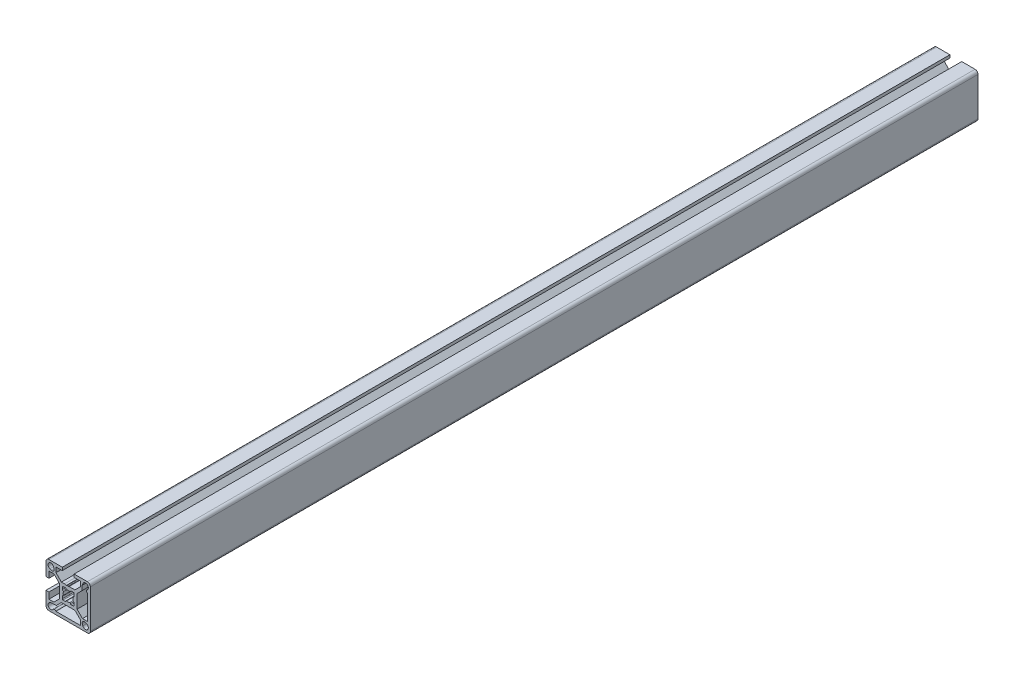
from build123d import *

# Parameters (mm, degrees)
ESTRUSIONE_ESTRUSIONE1_DEPTH = 600


with BuildPart() as part:
    # Schizzo1 → Estrusione-Estrusione1 (new body)
    with BuildSketch(Plane(origin=(0, 0, -600), x_dir=(-1, 0, 0), z_dir=(0, 0, -1))):
        with BuildLine():
            Line((-15, 13), (-15, -13))
            ThreePointArc((-15, -13), (-14.414213562, -14.414213562), (-13, -15))
            Line((-13, -15), (13, -15))
            ThreePointArc((13, -15), (14.414213562, -14.414213562), (15, -13))
            Line((15, -13), (15, -4))
            Line((15, -4), (13, -4))
            Line((13, -4), (13, -8.25))
            Line((13, -8.25), (9.664213562, -8.25))
            add(Edge.make_bspline(
                [(9.664213562, -8.25), (8.442809042, -7.028595479), (7.221404521, -5.807190958), (6, -4.585786438)],
                knots=[0, 0, 0, 0, 1, 1, 1, 1], degree=3))
            Line((6, -4.585786438), (6, -2.5))
            Line((6, -2.5), (5.750976629, -1.218885816))
            Line((5.750976629, -1.218885816), (5.933012788, -0.90358969))
            ThreePointArc((5.933012788, -0.90358969), (6, -0.653589753), (5.933012702, -0.403589838))
            Line((5.933012702, -0.403589838), (5.7, 0))
            Line((5.7, 0), (5.933012702, 0.403589838))
            ThreePointArc((5.933012702, 0.403589838), (5.982962913, 0.524180316), (6, 0.653589838))
            Line((6, 0.653589838), (6, 4.585786438))
            add(Edge.make_bspline(
                [(6, 4.585786438), (7.221404521, 5.807190958), (8.442809042, 7.028595479), (9.664213562, 8.25)],
                knots=[0, 0, 0, 0, 1, 1, 1, 1], degree=3))
            Line((9.664213562, 8.25), (13, 8.25))
            Line((13, 8.25), (13, 4))
            Line((13, 4), (15, 4))
            Line((15, 4), (15, 13))
            ThreePointArc((15, 13), (14.414213562, 14.414213562), (13, 15))
            Line((13, 15), (4, 15))
            Line((4, 15), (4, 13))
            Line((4, 13), (8.25, 13))
            Line((8.25, 13), (8.25, 9.664213562))
            add(Edge.make_bspline(
                [(8.25, 9.664213562), (7.028595479, 8.442809042), (5.807190958, 7.221404521), (4.585786438, 6)],
                knots=[0, 0, 0, 0, 1, 1, 1, 1], degree=3))
            Line((4.585786438, 6), (2.5, 6))
            Line((2.5, 6), (1.218885629, 5.750976592))
            Line((1.218885629, 5.750976592), (0.903589838, 5.933012702))
            ThreePointArc((0.903589838, 5.933012702), (0.653589838, 6), (0.403589838, 5.933012702))
            Line((0.403589838, 5.933012702), (0, 5.7))
            Line((0, 5.7), (-0.403589838, 5.933012702))
            ThreePointArc((-0.403589838, 5.933012702), (-0.524180316, 5.982962913), (-0.653589838, 6))
            Line((-0.653589838, 6), (-4.585786438, 6))
            add(Edge.make_bspline(
                [(-4.585786438, 6), (-5.807190958, 7.221404521), (-7.028595479, 8.442809042), (-8.25, 9.664213562)],
                knots=[0, 0, 0, 0, 1, 1, 1, 1], degree=3))
            Line((-8.25, 9.664213562), (-8.25, 13))
            Line((-8.25, 13), (-4, 13))
            Line((-4, 13), (-4, 15))
            Line((-4, 15), (-13, 15))
            ThreePointArc((-13, 15), (-14.414213562, 14.414213562), (-15, 13))
        make_face()
        with BuildLine():
            Line((12.349838066, 9.914583088), (11.34224826, 9.54785039))
            ThreePointArc((11.34224826, 9.54785039), (9.873470565, 9.873470565), (9.54785039, 11.34224826))
            Line((9.54785039, 11.34224826), (9.914583088, 12.349838066))
            ThreePointArc((9.914583088, 12.349838066), (13.043502884, 13.043502884), (12.349838066, 9.914583088))
        make_face(mode=Mode.SUBTRACT)
        with BuildLine():
            Line((-4.585786438, -6), (4.58, -6))
            add(Edge.make_bspline(
                [(4.58, -6), (5.73, -7.15), (6.88, -8.3), (8.03, -9.45)],
                knots=[0, 0, 0, 0, 1, 1, 1, 1], degree=3))
            Line((8.03, -9.45), (11.1, -9.45))
            Line((11.1, -9.45), (12.361944654, -9.919036981))
            ThreePointArc((12.361944654, -9.919036981), (13.194761433, -12.872897378), (10.127586207, -12.766543418))
            ThreePointArc((10.127586207, -12.766543418), (9.169403304, -12.336446483), (8.355281336, -13))
            Line((8.355281336, -13), (-8.25, -13))
            Line((-8.25, -13), (-8.25, -9.664213562))
            add(Edge.make_bspline(
                [(-8.25, -9.664213562), (-7.028595479, -8.442809042), (-5.807190958, -7.221404521), (-4.585786438, -6)],
                knots=[0, 0, 0, 0, 1, 1, 1, 1], degree=3))
        make_face(mode=Mode.SUBTRACT)
        with BuildLine():
            Line((-9.919036981, 12.361944654), (-9.45, 11.1))
            Line((-9.45, 11.1), (-9.45, 8.03))
            add(Edge.make_bspline(
                [(-9.45, 8.03), (-8.3, 6.88), (-7.15, 5.73), (-6, 4.58)],
                knots=[0, 0, 0, 0, 1, 1, 1, 1], degree=3))
            Line((-6, 4.58), (-6, -4.585786438))
            add(Edge.make_bspline(
                [(-6, -4.585786438), (-7.221404521, -5.807190958), (-8.442809042, -7.028595479), (-9.664213562, -8.25)],
                knots=[0, 0, 0, 0, 1, 1, 1, 1], degree=3))
            Line((-9.664213562, -8.25), (-13, -8.25))
            Line((-13, -8.25), (-13, 8.355281336))
            ThreePointArc((-13, 8.355281336), (-12.336446483, 9.169403304), (-12.766543418, 10.127586207))
            ThreePointArc((-12.766543418, 10.127586207), (-12.872897378, 13.194761433), (-9.919036981, 12.361944654))
        make_face(mode=Mode.SUBTRACT)
        with BuildLine():
            Line((-9.54785039, -11.34224826), (-9.914583088, -12.349838066))
            ThreePointArc((-9.914583088, -12.349838066), (-13.043502884, -13.043502884), (-12.349838066, -9.914583088))
            Line((-12.349838066, -9.914583088), (-11.34224826, -9.54785039))
            ThreePointArc((-11.34224826, -9.54785039), (-9.873470565, -9.873470565), (-9.54785039, -11.34224826))
        make_face(mode=Mode.SUBTRACT)
        with BuildLine():
            Line((4, 3.5), (4, 2))
            ThreePointArc((4, 2), (3.879005736, 1.673879391), (3.574581393, 1.505593673))
            ThreePointArc((3.574581393, 1.505593673), (3.295837094, 1.323326833), (3.251694243, 0.993219284))
            ThreePointArc((3.251694243, 0.993219284), (3.4, 0), (3.251694243, -0.993219284))
            ThreePointArc((3.251694243, -0.993219284), (3.295837094, -1.323326833), (3.574581393, -1.505593673))
            ThreePointArc((3.574581393, -1.505593673), (3.879005736, -1.673879391), (4, -2))
            Line((4, -2), (4, -3.5))
            ThreePointArc((4, -3.5), (3.853553391, -3.853553391), (3.5, -4))
            Line((3.5, -4), (2, -4))
            ThreePointArc((2, -4), (1.673879391, -3.879005736), (1.505593673, -3.574581393))
            ThreePointArc((1.505593673, -3.574581393), (1.323326833, -3.295837094), (0.993219284, -3.251694243))
            ThreePointArc((0.993219284, -3.251694243), (0, -3.4), (-0.993219284, -3.251694243))
            ThreePointArc((-0.993219284, -3.251694243), (-1.323326833, -3.295837094), (-1.505593673, -3.574581393))
            ThreePointArc((-1.505593673, -3.574581393), (-1.673879391, -3.879005736), (-2, -4))
            Line((-2, -4), (-3.5, -4))
            ThreePointArc((-3.5, -4), (-3.853553391, -3.853553391), (-4, -3.5))
            Line((-4, -3.5), (-4, -2))
            ThreePointArc((-4, -2), (-3.879005736, -1.673879391), (-3.574581393, -1.505593673))
            ThreePointArc((-3.574581393, -1.505593673), (-3.295837094, -1.323326833), (-3.251694243, -0.993219284))
            ThreePointArc((-3.251694243, -0.993219284), (-3.4, 0), (-3.251694243, 0.993219284))
            ThreePointArc((-3.251694243, 0.993219284), (-3.295837094, 1.323326833), (-3.574581393, 1.505593673))
            ThreePointArc((-3.574581393, 1.505593673), (-3.879005736, 1.673879391), (-4, 2))
            Line((-4, 2), (-4, 3.5))
            ThreePointArc((-4, 3.5), (-3.853553391, 3.853553391), (-3.5, 4))
            Line((-3.5, 4), (-2, 4))
            ThreePointArc((-2, 4), (-1.673879391, 3.879005736), (-1.505593673, 3.574581393))
            ThreePointArc((-1.505593673, 3.574581393), (-1.323326833, 3.295837094), (-0.993219284, 3.251694243))
            ThreePointArc((-0.993219284, 3.251694243), (0, 3.4), (0.993219284, 3.251694243))
            ThreePointArc((0.993219284, 3.251694243), (1.323326833, 3.295837094), (1.505593673, 3.574581393))
            ThreePointArc((1.505593673, 3.574581393), (1.673879391, 3.879005736), (2, 4))
            Line((2, 4), (3.5, 4))
            ThreePointArc((3.5, 4), (3.853553391, 3.853553391), (4, 3.5))
        make_face(mode=Mode.SUBTRACT)
    extrude(amount=-ESTRUSIONE_ESTRUSIONE1_DEPTH)


solid = part.part
